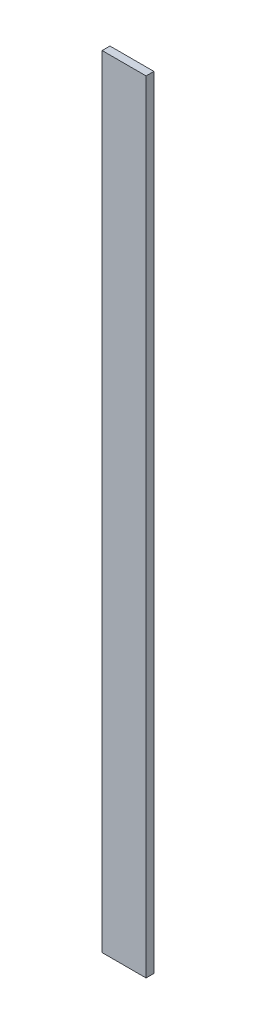
from build123d import *

# Parameters (mm, degrees)
SKETCH2_W           = 14.2875
SKETCH2_H           = 254
BOSS_EXTRUDE1_DEPTH = 2.54


with BuildPart() as part:
    # Sketch2 → Boss-Extrude1 (new body)
    with BuildSketch(Plane.XY):
        with Locations((0, 41.827893901)):
            Rectangle(SKETCH2_W, SKETCH2_H)
    extrude(amount=BOSS_EXTRUDE1_DEPTH)


solid = part.part
